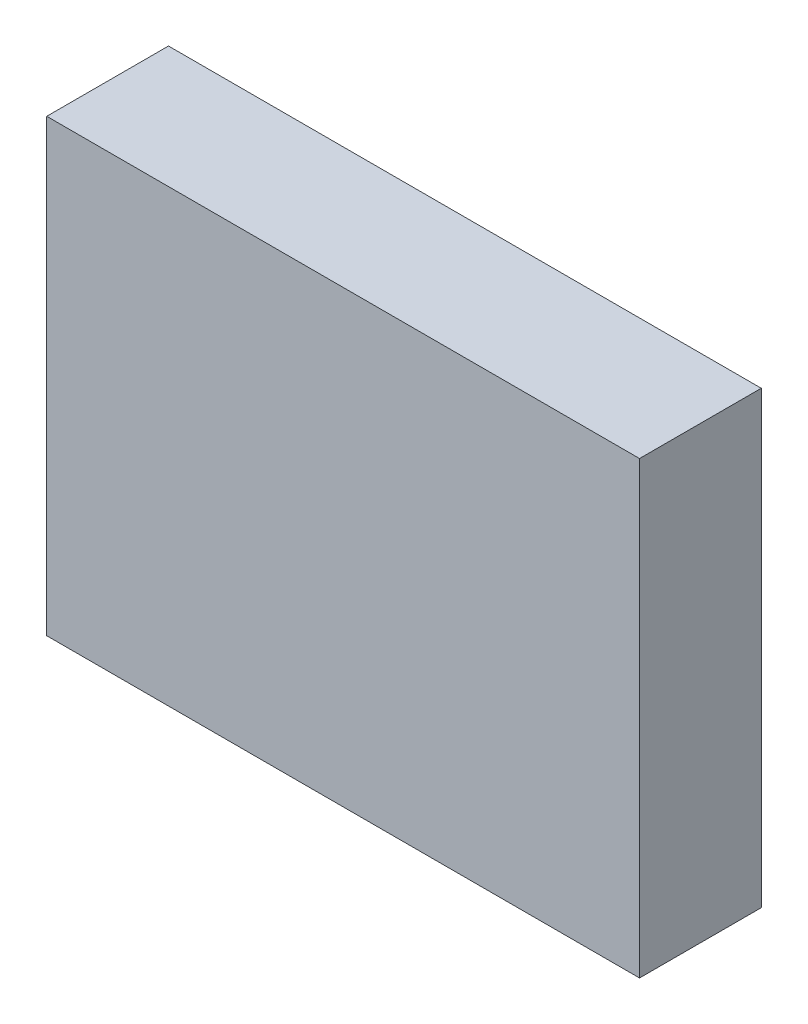
from build123d import *

# Parameters (mm, degrees)
SKETCH1_W           = 22.4
SKETCH1_H           = 17
BOSS_EXTRUDE1_DEPTH = 4.6


with BuildPart() as part:
    # Sketch1 → Boss-Extrude1 (new body)
    with BuildSketch(Plane.XY):
        with Locations((11.2, 8.5)):
            Rectangle(SKETCH1_W, SKETCH1_H)
    extrude(amount=BOSS_EXTRUDE1_DEPTH)


solid = part.part
